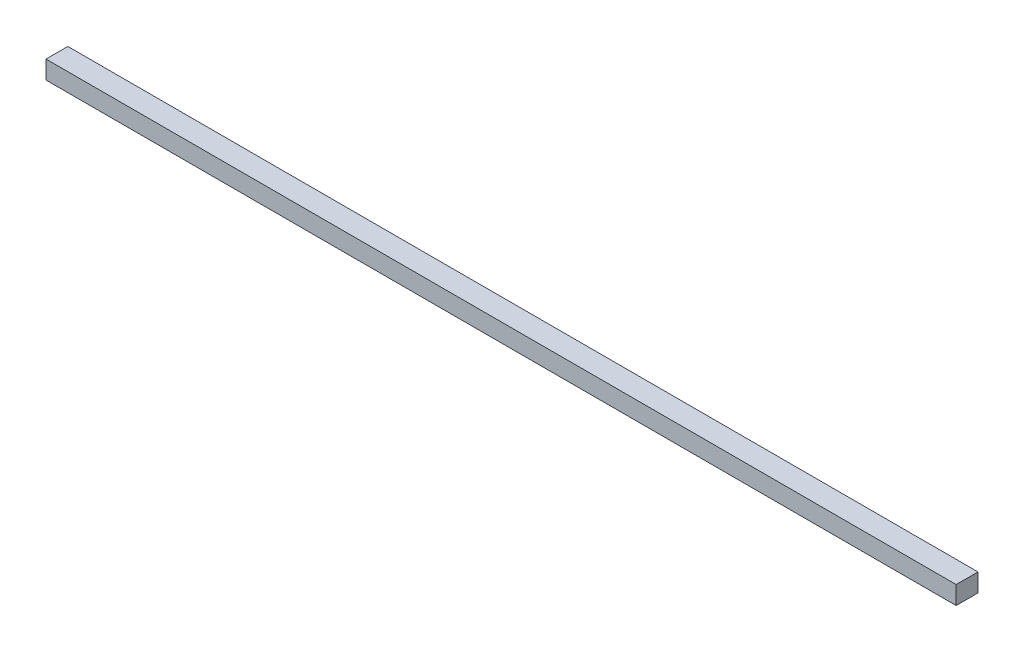
from build123d import *

# Parameters (mm, degrees)
SKETCH1_W           = 500
SKETCH1_H           = 12
BOSS_EXTRUDE1_DEPTH = 10


with BuildPart() as part:
    # Sketch1 → Boss-Extrude1 (new body)
    with BuildSketch(Plane(origin=(0, 0, 0), x_dir=(1, 0, 0), z_dir=(0, 1, 0))):
        Rectangle(SKETCH1_W, SKETCH1_H)
    extrude(amount=BOSS_EXTRUDE1_DEPTH)


solid = part.part
